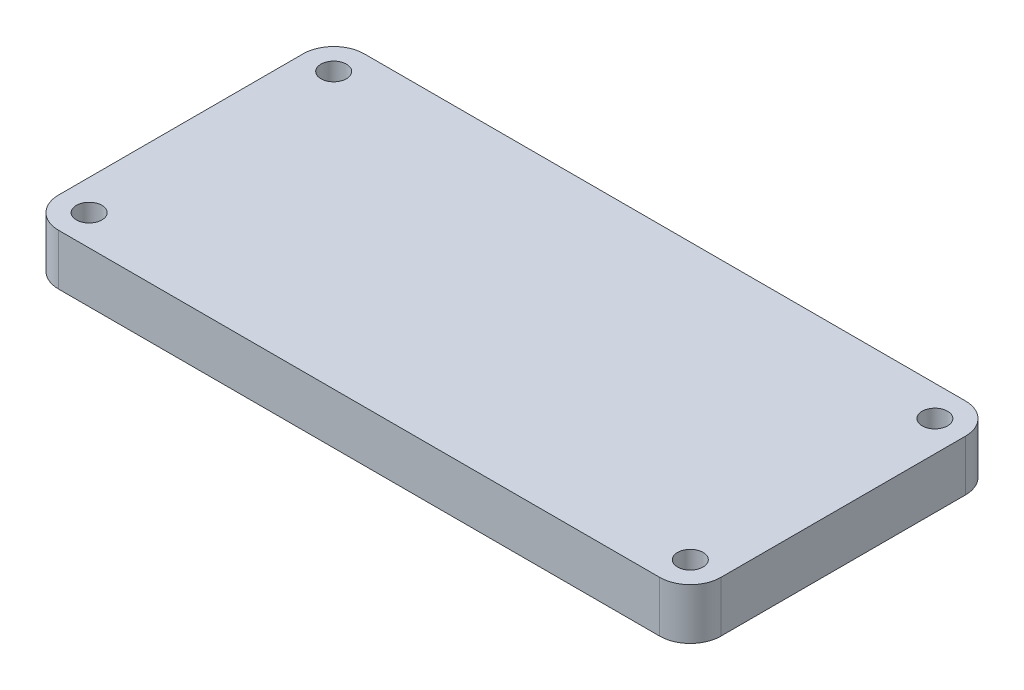
from build123d import *

# Parameters (mm, degrees)
SKETCH1_R           = 1.25
BOSS_EXTRUDE1_DEPTH = 5


with BuildPart() as part:
    # Sketch1 → Boss-Extrude1 (new body)
    with BuildSketch(Plane(origin=(0, 0, 0), x_dir=(1, 0, 0), z_dir=(0, 1, 0))):
        with BuildLine():
            Line((-29.5, -15), (29.5, -15))
            ThreePointArc((29.5, -15), (31.621320344, -14.121320344), (32.5, -12))
            Line((32.5, -12), (32.5, 12))
            ThreePointArc((32.5, 12), (31.621320344, 14.121320344), (29.5, 15))
            Line((29.5, 15), (-29.5, 15))
            ThreePointArc((-29.5, 15), (-31.621320344, 14.121320344), (-32.5, 12))
            Line((-32.5, 12), (-32.5, -12))
            ThreePointArc((-32.5, -12), (-31.621320344, -14.121320344), (-29.5, -15))
        make_face()
        with Locations((-29.5, 12)):
            Circle(SKETCH1_R, mode=Mode.SUBTRACT)
        with Locations((29.5, 12)):
            Circle(SKETCH1_R, mode=Mode.SUBTRACT)
        with Locations((29.5, -12)):
            Circle(SKETCH1_R, mode=Mode.SUBTRACT)
        with Locations((-29.5, -12)):
            Circle(SKETCH1_R, mode=Mode.SUBTRACT)
    extrude(amount=BOSS_EXTRUDE1_DEPTH)


solid = part.part
